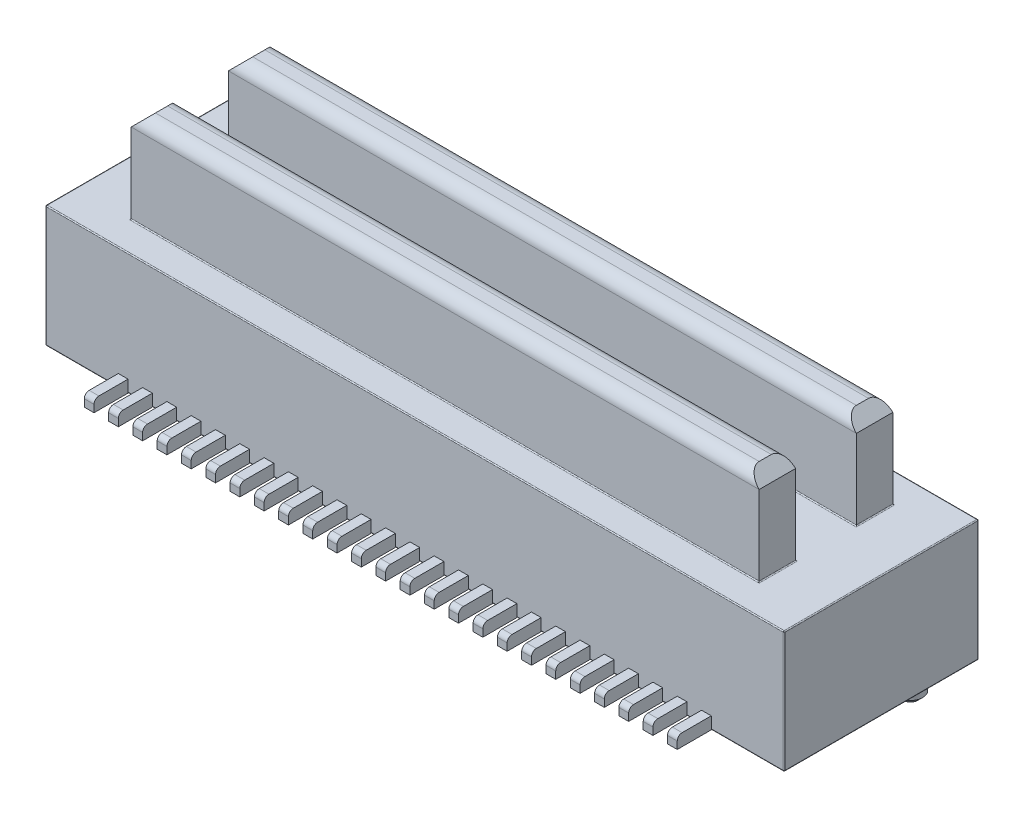
from build123d import *

# Parameters (mm, degrees)
SKETCH1_W           = 15.2
SKETCH1_H           = 4
BOSS_EXTRUDE1_DEPTH = 2.5
BOSS_EXTRUDE2_START = -2.5
SKETCH2_W           = 12.92
SKETCH2_H           = 0.75
BOSS_EXTRUDE2_DEPTH = 4.4
CHAMFER1_SIZE       = 0.25
FILLET1_R           = 0.25
FILLET2_R           = 0.02
SKETCH1_3_W         = 0.2
SKETCH1_3_H         = 0.7
BOSS_EXTRUDE3_DEPTH = 0.25
FILLET3_R           = 0.1
SKETCH1_4_R         = 0.25
BOSS_EXTRUDE4_DEPTH = 0.6
CHAMFER2_SIZE       = 0.1


with BuildPart() as part:
    # Sketch1 → Boss-Extrude1 (new body)
    with BuildSketch(Plane(origin=(0, 0, 0), x_dir=(1, 0, 0), z_dir=(0, 1, 0))):
        Rectangle(SKETCH1_W, SKETCH1_H)
    extrude(amount=BOSS_EXTRUDE1_DEPTH)

    # Sketch2 → Boss-Extrude2 (add)
    with BuildSketch(Plane(origin=(0, 2.5, 0), x_dir=(1, 0, 0), z_dir=(0, 1, 0)).offset(BOSS_EXTRUDE2_START)):
        with Locations((0, -1)):
            Rectangle(SKETCH2_W, SKETCH2_H)
        with Locations((0, 1)):
            Rectangle(SKETCH2_W, SKETCH2_H)
    extrude(amount=BOSS_EXTRUDE2_DEPTH)

    # Chamfer1
    chamfer1_edges = [part.edges().sort_by_distance(p)[0] for p in [
        (-6.46, 4.4, 1),
        (6.46, 4.4, 1),
        (-6.46, 4.4, -1),
        (6.46, 4.4, -1),
    ]]
    chamfer(chamfer1_edges, length=CHAMFER1_SIZE)

    # Fillet1
    fillet1_edges = [part.edges().sort_by_distance(p)[0] for p in [
        (0, 4.4, -1.375),
        (0, 4.4, -0.625),
        (0, 4.4, 0.625),
        (0, 4.4, 1.375),
    ]]
    fillet(fillet1_edges, radius=FILLET1_R)

    # Fillet2
    fillet2_edges = [part.edges().sort_by_distance(p)[0] for p in [
        (7.6, 0, 0),
        (0, 0, 2),
        (-7.6, 0, 0),
        (0, 0, -2),
        (7.6, 1.25, -2),
        (7.6, 1.25, 2),
        (-7.6, 1.25, 2),
        (-7.6, 1.25, -2),
        (-7.6, 2.5, 0),
        (0, 2.5, 2),
        (0, 2.5, -2),
        (0, 2.5, 0.625),
        (-6.46, 2.5, 1),
        (0, 2.5, 1.375),
        (6.46, 2.5, 1),
        (7.6, 2.5, 0),
        (0, 2.5, -1.375),
        (-6.46, 2.5, -1),
        (0, 2.5, -0.625),
        (6.46, 2.5, -1),
    ]]
    fillet(fillet2_edges, radius=FILLET2_R)

    # Sketch1_3 → Boss-Extrude3 (add)
    with BuildSketch(Plane(origin=(0, 0, 0), x_dir=(1, 0, 0), z_dir=(0, 1, 0))):
        with Locations((-6, -2.35)):
            Rectangle(SKETCH1_3_W, SKETCH1_3_H)
        with Locations((-5.5, -2.35)):
            Rectangle(SKETCH1_3_W, SKETCH1_3_H)
        with Locations((-5, -2.35)):
            Rectangle(SKETCH1_3_W, SKETCH1_3_H)
        with Locations((-4.5, -2.35)):
            Rectangle(SKETCH1_3_W, SKETCH1_3_H)
        with Locations((-4, -2.35)):
            Rectangle(SKETCH1_3_W, SKETCH1_3_H)
        with Locations((-3.5, -2.35)):
            Rectangle(SKETCH1_3_W, SKETCH1_3_H)
        with Locations((-3, -2.35)):
            Rectangle(SKETCH1_3_W, SKETCH1_3_H)
        with Locations((-2.5, -2.35)):
            Rectangle(SKETCH1_3_W, SKETCH1_3_H)
        with Locations((-2, -2.35)):
            Rectangle(SKETCH1_3_W, SKETCH1_3_H)
        with Locations((-1.5, -2.35)):
            Rectangle(SKETCH1_3_W, SKETCH1_3_H)
        with Locations((-1, -2.35)):
            Rectangle(SKETCH1_3_W, SKETCH1_3_H)
        with Locations((-0.5, -2.35)):
            Rectangle(SKETCH1_3_W, SKETCH1_3_H)
        with Locations((0, -2.35)):
            Rectangle(SKETCH1_3_W, SKETCH1_3_H)
        with Locations((0.5, -2.35)):
            Rectangle(SKETCH1_3_W, SKETCH1_3_H)
        with Locations((1, -2.35)):
            Rectangle(SKETCH1_3_W, SKETCH1_3_H)
        with Locations((1.5, -2.35)):
            Rectangle(SKETCH1_3_W, SKETCH1_3_H)
        with Locations((2, -2.35)):
            Rectangle(SKETCH1_3_W, SKETCH1_3_H)
        with Locations((2.5, -2.35)):
            Rectangle(SKETCH1_3_W, SKETCH1_3_H)
        with Locations((3, -2.35)):
            Rectangle(SKETCH1_3_W, SKETCH1_3_H)
        with Locations((3.5, -2.35)):
            Rectangle(SKETCH1_3_W, SKETCH1_3_H)
        with Locations((4, -2.35)):
            Rectangle(SKETCH1_3_W, SKETCH1_3_H)
        with Locations((4.5, -2.35)):
            Rectangle(SKETCH1_3_W, SKETCH1_3_H)
        with Locations((5, -2.35)):
            Rectangle(SKETCH1_3_W, SKETCH1_3_H)
        with Locations((5.5, -2.35)):
            Rectangle(SKETCH1_3_W, SKETCH1_3_H)
        with Locations((6, -2.35)):
            Rectangle(SKETCH1_3_W, SKETCH1_3_H)
        with Locations((6, 2.35)):
            Rectangle(SKETCH1_3_W, SKETCH1_3_H)
        with Locations((5.5, 2.35)):
            Rectangle(SKETCH1_3_W, SKETCH1_3_H)
        with Locations((5, 2.35)):
            Rectangle(SKETCH1_3_W, SKETCH1_3_H)
        with Locations((4.5, 2.35)):
            Rectangle(SKETCH1_3_W, SKETCH1_3_H)
        with Locations((4, 2.35)):
            Rectangle(SKETCH1_3_W, SKETCH1_3_H)
        with Locations((3.5, 2.35)):
            Rectangle(SKETCH1_3_W, SKETCH1_3_H)
        with Locations((3, 2.35)):
            Rectangle(SKETCH1_3_W, SKETCH1_3_H)
        with Locations((2.5, 2.35)):
            Rectangle(SKETCH1_3_W, SKETCH1_3_H)
        with Locations((2, 2.35)):
            Rectangle(SKETCH1_3_W, SKETCH1_3_H)
        with Locations((1.5, 2.35)):
            Rectangle(SKETCH1_3_W, SKETCH1_3_H)
        with Locations((1, 2.35)):
            Rectangle(SKETCH1_3_W, SKETCH1_3_H)
        with Locations((0.5, 2.35)):
            Rectangle(SKETCH1_3_W, SKETCH1_3_H)
        with Locations((0, 2.35)):
            Rectangle(SKETCH1_3_W, SKETCH1_3_H)
        with Locations((-0.5, 2.35)):
            Rectangle(SKETCH1_3_W, SKETCH1_3_H)
        with Locations((-1, 2.35)):
            Rectangle(SKETCH1_3_W, SKETCH1_3_H)
        with Locations((-1.5, 2.35)):
            Rectangle(SKETCH1_3_W, SKETCH1_3_H)
        with Locations((-2, 2.35)):
            Rectangle(SKETCH1_3_W, SKETCH1_3_H)
        with Locations((-2.5, 2.35)):
            Rectangle(SKETCH1_3_W, SKETCH1_3_H)
        with Locations((-3, 2.35)):
            Rectangle(SKETCH1_3_W, SKETCH1_3_H)
        with Locations((-3.5, 2.35)):
            Rectangle(SKETCH1_3_W, SKETCH1_3_H)
        with Locations((-4, 2.35)):
            Rectangle(SKETCH1_3_W, SKETCH1_3_H)
        with Locations((-4.5, 2.35)):
            Rectangle(SKETCH1_3_W, SKETCH1_3_H)
        with Locations((-5, 2.35)):
            Rectangle(SKETCH1_3_W, SKETCH1_3_H)
        with Locations((-5.5, 2.35)):
            Rectangle(SKETCH1_3_W, SKETCH1_3_H)
        with Locations((-6, 2.35)):
            Rectangle(SKETCH1_3_W, SKETCH1_3_H)
    extrude(amount=BOSS_EXTRUDE3_DEPTH)

    # Fillet3
    fillet3_edges = [part.edges().sort_by_distance(p)[0] for p in [
        (-6, 0.25, 2.7),
        (-5.5, 0.25, 2.7),
        (-5, 0.25, 2.7),
        (-4.5, 0.25, 2.7),
        (-4, 0.25, 2.7),
        (-3.5, 0.25, 2.7),
        (-3, 0.25, 2.7),
        (-2.5, 0.25, 2.7),
        (-2, 0.25, 2.7),
        (-1.5, 0.25, 2.7),
        (-1, 0.25, 2.7),
        (-0.5, 0.25, 2.7),
        (0, 0.25, 2.7),
        (0.5, 0.25, 2.7),
        (1, 0.25, 2.7),
        (1.5, 0.25, 2.7),
        (2, 0.25, 2.7),
        (2.5, 0.25, 2.7),
        (3, 0.25, 2.7),
        (3.5, 0.25, 2.7),
        (4, 0.25, 2.7),
        (4.5, 0.25, 2.7),
        (5, 0.25, 2.7),
        (5.5, 0.25, 2.7),
        (6, 0.25, 2.7),
        (6, 0.25, -2.7),
        (5.5, 0.25, -2.7),
        (5, 0.25, -2.7),
        (4.5, 0.25, -2.7),
        (4, 0.25, -2.7),
        (3.5, 0.25, -2.7),
        (3, 0.25, -2.7),
        (2.5, 0.25, -2.7),
        (2, 0.25, -2.7),
        (1.5, 0.25, -2.7),
        (1, 0.25, -2.7),
        (0.5, 0.25, -2.7),
        (0, 0.25, -2.7),
        (-0.5, 0.25, -2.7),
        (-1, 0.25, -2.7),
        (-1.5, 0.25, -2.7),
        (-2, 0.25, -2.7),
        (-2.5, 0.25, -2.7),
        (-3, 0.25, -2.7),
        (-3.5, 0.25, -2.7),
        (-4, 0.25, -2.7),
        (-4.5, 0.25, -2.7),
        (-5, 0.25, -2.7),
        (-5.5, 0.25, -2.7),
        (-6, 0.25, -2.7),
    ]]
    fillet(fillet3_edges, radius=FILLET3_R)

    # Sketch1_4 → Boss-Extrude4 (add)
    with BuildSketch(Plane(origin=(0, 0, 0), x_dir=(1, 0, 0), z_dir=(0, 1, 0))):
        with Locations((6.95, 1.25)):
            Circle(SKETCH1_4_R)
        with Locations((-6.95, 1.25)):
            Circle(SKETCH1_4_R)
    extrude(amount=-BOSS_EXTRUDE4_DEPTH)

    # Chamfer2
    chamfer2_edges = [part.edges().sort_by_distance(p)[0] for p in [
        (6.7, -0.6, -1.25),
        (-7.2, -0.6, -1.25),
    ]]
    chamfer(chamfer2_edges, length=CHAMFER2_SIZE)


solid = part.part
